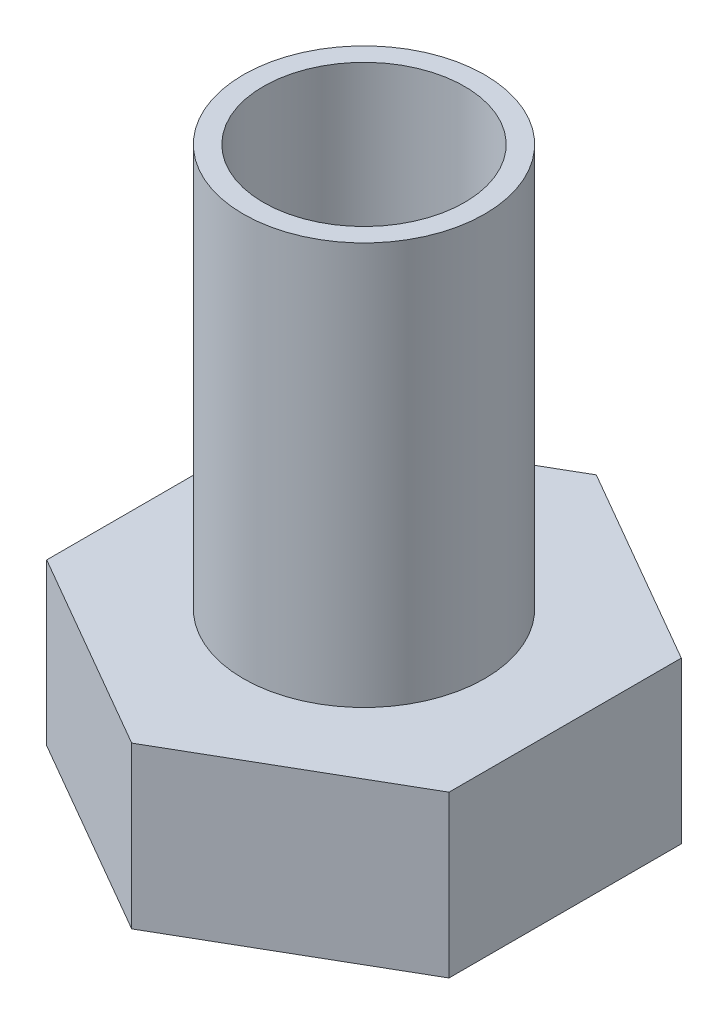
from build123d import *

# Parameters (mm, degrees)
SKETCH1_R           = 3
SKETCH1_R_2         = 2.5
BOSS_EXTRUDE1_DEPTH = 10
BOSS_EXTRUDE2_DEPTH = 4


with BuildPart() as part:
    # Sketch1 → Boss-Extrude1 (new body)
    with BuildSketch(Plane(origin=(0, 0, 0), x_dir=(1, 0, 0), z_dir=(0, 1, 0))):
        Circle(SKETCH1_R)
        Circle(SKETCH1_R_2, mode=Mode.SUBTRACT)
    extrude(amount=BOSS_EXTRUDE1_DEPTH)

    # Sketch2 → Boss-Extrude2 (add)
    with BuildSketch(Plane.XZ):
        Polygon((0, 5.773502692), (-5, 2.886751346), (-5, -2.886751346), (0, -5.773502692), (5, -2.886751346), (5, 2.886751346), align=None)
    extrude(amount=BOSS_EXTRUDE2_DEPTH)


solid = part.part
